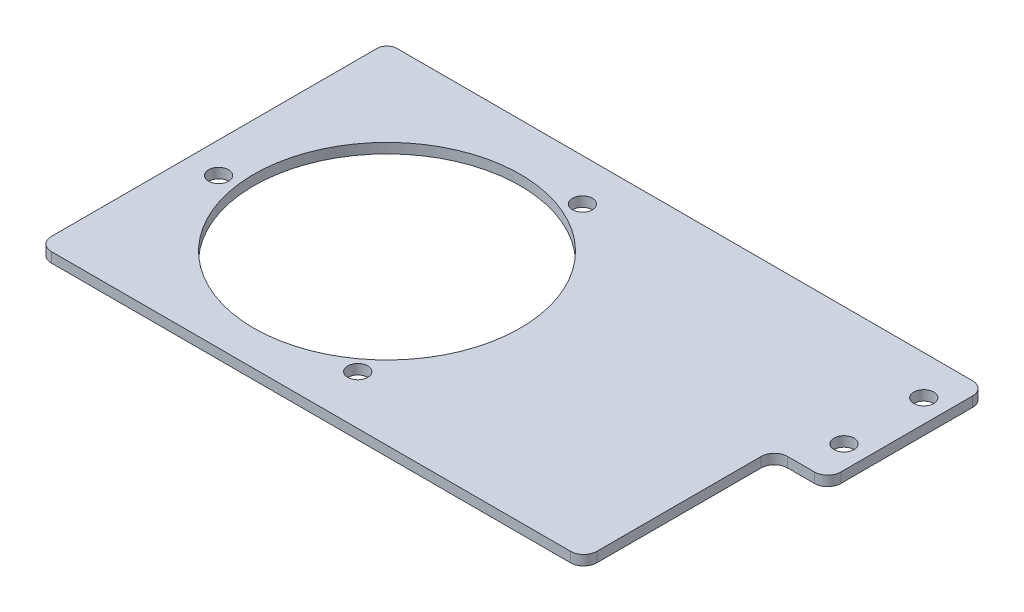
from build123d import *

# Parameters (mm, degrees)
SKETCH5_R           = 84.7725
SKETCH5_R_2         = 6.35
BOSS_EXTRUDE1_DEPTH = 6.35


with BuildPart() as part:
    # Sketch5 → Boss-Extrude1 (new body)
    with BuildSketch(Plane(origin=(0, 0, 0), x_dir=(1, 0, 0), z_dir=(0, 1, 0))):
        with BuildLine():
            Line((-108.51132569, 114.857435108), (257.591051155, 114.857435108))
            ThreePointArc((257.591051155, 114.857435108), (263.497362796, 112.410960723), (265.943837181, 106.504649083))
            Line((265.943837181, 106.504649083), (265.943837181, 22.684649083))
            ThreePointArc((265.943837181, 22.684649083), (263.497362796, 16.778337443), (257.591051155, 14.331863057))
            Line((257.591051155, 14.331863057), (240.397032386, 14.331863057))
            ThreePointArc((240.397032386, 14.331863057), (234.490720746, 11.885388672), (232.044246361, 5.979077032))
            Line((232.044246361, 5.979077032), (232.044246361, -98.583895379))
            ThreePointArc((232.044246361, -98.583895379), (229.597771976, -104.490207019), (223.691460335, -106.936681404))
            Line((223.691460335, -106.936681404), (-106.508539665, -106.936681404))
            ThreePointArc((-106.508539665, -106.936681404), (-112.414851305, -104.490207019), (-114.86132569, -98.583895379))
            Line((-114.86132569, -98.583895379), (-114.86132569, 108.507435108))
            ThreePointArc((-114.86132569, 108.507435108), (-113.001453751, 112.997563169), (-108.51132569, 114.857435108))
        make_face()
        Circle(SKETCH5_R, mode=Mode.SUBTRACT)
        with Locations((251.46, 89.968152547)):
            Circle(SKETCH5_R_2, mode=Mode.SUBTRACT)
        with Locations((251.46, 39.221145619)):
            Circle(SKETCH5_R_2, mode=Mode.SUBTRACT)
        with Locations((-95.238376165, -11.844376537)):
            Circle(SKETCH5_R_2, mode=Mode.SUBTRACT)
        with Locations((57.035275027, -75.64676797)):
            Circle(SKETCH5_R_2, mode=Mode.SUBTRACT)
        with Locations((36.152941234, 88.127278006)):
            Circle(SKETCH5_R_2, mode=Mode.SUBTRACT)
    extrude(amount=-BOSS_EXTRUDE1_DEPTH)


solid = part.part
